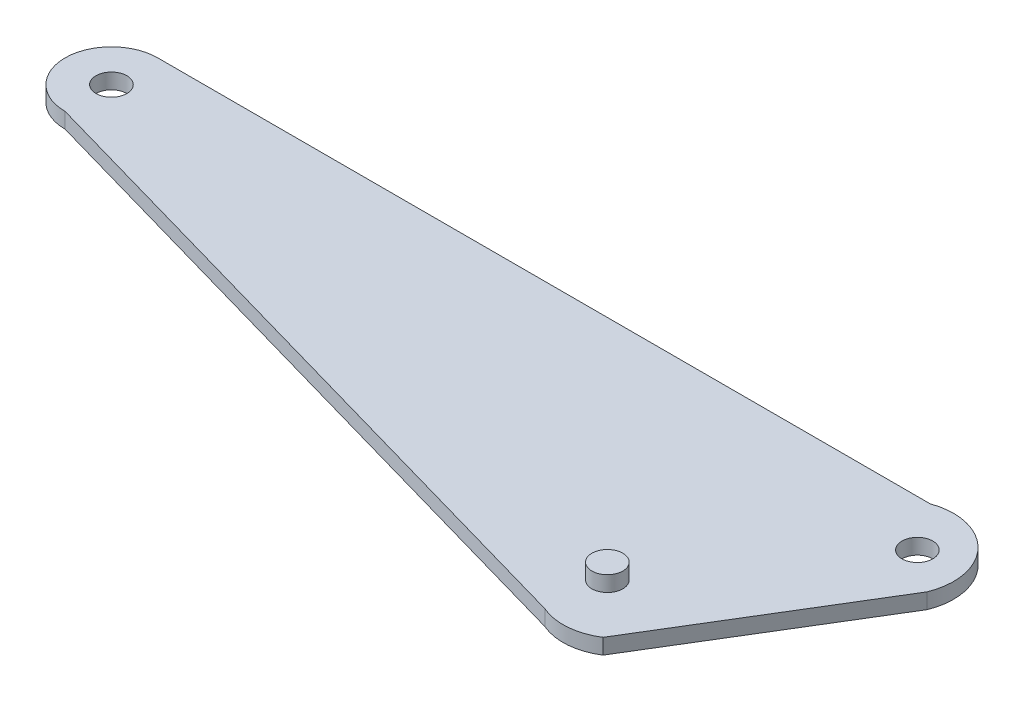
from build123d import *

# Parameters (mm, degrees)
SKETCH1_R           = 1
BOSS_EXTRUDE4_DEPTH = 1
SKETCH4_R           = 1
BOSS_EXTRUDE5_DEPTH = 1


with BuildPart() as part:
    # Sketch1 → Boss-Extrude4 (new body)
    with BuildSketch(Plane(origin=(0, 0, 0), x_dir=(1, 0, 0), z_dir=(0, 1, 0))):
        with BuildLine():
            Line((-26.085, 3), (23.915, 3))
            ThreePointArc((23.915, 3), (27.965705649, 2.046261886), (28.743665769, -2.041844117))
            Line((28.743665769, -2.041844117), (20.812640503, -15.067570319))
            ThreePointArc((20.812640503, -15.067570319), (19.103092744, -15.647684769), (17.322461075, -15.350300892))
            Line((17.322461075, -15.350300892), (-26.085, -3))
            ThreePointArc((-26.085, -3), (-29.085, 0), (-26.085, 3))
        make_face()
        with Locations((-26.085, 0)):
            Circle(SKETCH1_R, mode=Mode.SUBTRACT)
        with Locations((26.085, 0)):
            Circle(SKETCH1_R, mode=Mode.SUBTRACT)
    extrude(amount=BOSS_EXTRUDE4_DEPTH)

    # Sketch4 → Boss-Extrude5 (add)
    with BuildSketch(Plane(origin=(0, 1, 0), x_dir=(1, 0, 0), z_dir=(0, 1, 0))):
        with Locations((17.732709605, -11.715326645)):
            Circle(SKETCH4_R)
    extrude(amount=BOSS_EXTRUDE5_DEPTH)


solid = part.part
